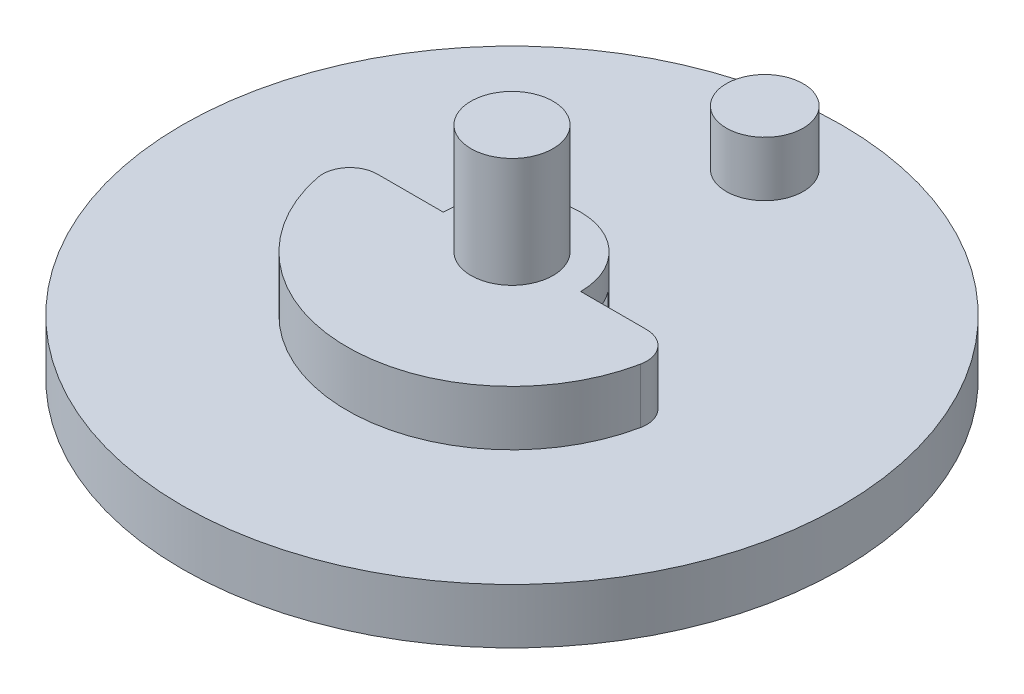
from build123d import *

# Parameters (mm, degrees)
SKETCH1_R                = 12
BOSS_EXTRUDE1_DEPTH      = 2
SKETCH2_R                = 1.5
BOSS_EXTRUDE2_DEPTH      = 2
SKETCH3_R                = 1.5
CUT_EXTRUDE1_DEPTH       = 5
SKETCH4_R                = 4
CUT_EXTRUDE2_DEPTH       = 2
SKETCH5_R                = 1.5
CUT_EXTRUDE3_DEPTH       = 2
SKETCH6_R                = 1.4
BOSS_EXTRUDE3_DEPTH      = 2
SKETCH7_R                = 1.6
CUT_EXTRUDE4_DEPTH       = 2
FILLET1_R                = 1
SKETCH8_R                = 4
BOSS_EXTRUDE7_DEPTH      = 5
SKETCH9_R                = 1.6
BOSS_EXTRUDE8_DEPTH      = 6
BOSS_EXTRUDE8_DEPTH_BACK = 2
SKETCH10_R               = 1.6
SKETCH10_R_2             = 1.495
CUT_EXTRUDE5_DEPTH       = 6
SKETCH11_R               = 4
BOSS_EXTRUDE9_DEPTH      = 2
CUT_EXTRUDE6_DEPTH       = 8
SKETCH13_R               = 6.833450219
CUT_EXTRUDE7_DEPTH       = 1
SKETCH14_R               = 7.033053892
CUT_EXTRUDE8_DEPTH       = 1
SKETCH15_R               = 8.776668046
CUT_EXTRUDE9_DEPTH       = 0.5
CUT_EXTRUDE10_DEPTH      = 2
CUT_EXTRUDE11_DEPTH      = 2


with BuildPart() as part:
    # Sketch1 → Boss-Extrude1 (new body)
    with BuildSketch(Plane(origin=(0, 0, 0), x_dir=(1, 0, 0), z_dir=(0, 1, 0))):
        Circle(SKETCH1_R)
    extrude(amount=BOSS_EXTRUDE1_DEPTH)

    # Sketch2 → Boss-Extrude2 (add)
    with BuildSketch(Plane(origin=(0, 2, 0), x_dir=(1, 0, 0), z_dir=(0, 1, 0))):
        with Locations((0, 9.5)):
            Circle(SKETCH2_R)
        with BuildLine():
            Line((-6, 0), (6, 0))
            ThreePointArc((6, 0), (0, -6), (-6, 0))
        make_face()
    extrude(amount=BOSS_EXTRUDE2_DEPTH)

    # Sketch3 → Cut-Extrude1 (cut)
    with BuildSketch(Plane.XZ):
        Circle(SKETCH3_R)
    extrude(amount=-CUT_EXTRUDE1_DEPTH, mode=Mode.SUBTRACT)

    # Sketch4 → Cut-Extrude2 (cut)
    with BuildSketch(Plane(origin=(0, 2, 0), x_dir=(1, 0, 0), z_dir=(0, 1, 0))):
        Circle(SKETCH4_R)
    extrude(amount=CUT_EXTRUDE2_DEPTH, mode=Mode.SUBTRACT)

    # Sketch5 → Cut-Extrude3 (cut)
    with BuildSketch(Plane(origin=(0, 2, 0), x_dir=(1, 0, 0), z_dir=(0, 1, 0))):
        with Locations((0, 9.5)):
            Circle(SKETCH5_R)
    extrude(amount=CUT_EXTRUDE3_DEPTH, mode=Mode.SUBTRACT)

    # Sketch6 → Boss-Extrude3 (add)
    with BuildSketch(Plane(origin=(0, 2, 0), x_dir=(1, 0, 0), z_dir=(0, 1, 0))):
        with Locations((0, 9.2)):
            Circle(SKETCH6_R)
    extrude(amount=BOSS_EXTRUDE3_DEPTH)

    # Sketch7 → Cut-Extrude4 (cut)
    with BuildSketch(Plane(origin=(0, 2, 0), x_dir=(1, 0, 0), z_dir=(0, 1, 0))):
        Circle(SKETCH7_R)
    extrude(amount=-CUT_EXTRUDE4_DEPTH, mode=Mode.SUBTRACT)

    # Fillet1
    fillet1_edges = [part.edges().sort_by_distance(p)[0] for p in [
        (-6, 3, 0),
        (6, 3, 0),
    ]]
    fillet(fillet1_edges, radius=FILLET1_R)

    # Sketch8 → Boss-Extrude7 (add)
    with BuildSketch(Plane(origin=(0, 0, 0), x_dir=(-1, 0, 0), z_dir=(0, -1, 0))):
        Circle(SKETCH8_R)
        with BuildLine():
            ThreePointArc((0.556776436, -1.5), (0, -1.6), (-0.556776436, -1.5))
            Line((-0.556776436, -1.5), (-2, -1.5))
            ThreePointArc((-2, -1.5), (-2.5, 0), (-2, 1.5))
            Line((-2, 1.5), (-0.556776436, 1.5))
            ThreePointArc((-0.556776436, 1.5), (0, 1.6), (0.556776436, 1.5))
            Line((0.556776436, 1.5), (2, 1.5))
            ThreePointArc((2, 1.5), (2.5, 0), (2, -1.5))
            Line((2, -1.5), (0.556776436, -1.5))
        make_face(mode=Mode.SUBTRACT)
    extrude(amount=BOSS_EXTRUDE7_DEPTH)

    # Sketch9 → Boss-Extrude8 (add, two sides)
    with BuildSketch(Plane(origin=(0, 2, 0), x_dir=(1, 0, 0), z_dir=(0, 1, 0))) as boss_extrude8_sk:
        Circle(SKETCH9_R)
    extrude(amount=BOSS_EXTRUDE8_DEPTH)
    extrude(boss_extrude8_sk.sketch, amount=-BOSS_EXTRUDE8_DEPTH_BACK)

    # Sketch10 → Cut-Extrude5 (cut)
    with BuildSketch(Plane(origin=(0, 8, 0), x_dir=(1, 0, 0), z_dir=(0, 1, 0))):
        Circle(SKETCH10_R)
        Circle(SKETCH10_R_2, mode=Mode.SUBTRACT)
    extrude(amount=-CUT_EXTRUDE5_DEPTH, mode=Mode.SUBTRACT)

    # Sketch11 → Boss-Extrude9 (add)
    with BuildSketch(Plane(origin=(0, 2, 0), x_dir=(1, 0, 0), z_dir=(0, 1, 0))):
        Circle(SKETCH11_R)
    extrude(amount=BOSS_EXTRUDE9_DEPTH)

    # Sketch12 → Cut-Extrude6 (cut)
    with BuildSketch(Plane(origin=(0, -5, 0), x_dir=(-1, 0, 0), z_dir=(0, -1, 0))):
        with BuildLine():
            Line((2, -1.5), (0.556776436, -1.5))
            ThreePointArc((0.556776436, -1.5), (0, -1.6), (-0.556776436, -1.5))
            Line((-0.556776436, -1.5), (-2, -1.5))
            ThreePointArc((-2, -1.5), (-2.5, 0), (-2, 1.5))
            Line((-2, 1.5), (-0.556776436, 1.5))
            ThreePointArc((-0.556776436, 1.5), (0, 1.6), (0.556776436, 1.5))
            Line((0.556776436, 1.5), (2, 1.5))
            ThreePointArc((2, 1.5), (2.5, 0), (2, -1.5))
        make_face()
    extrude(amount=-CUT_EXTRUDE6_DEPTH, mode=Mode.SUBTRACT)

    # Sketch13 → Cut-Extrude7 (cut)
    with BuildSketch(Plane(origin=(0, -5, 0), x_dir=(-1, 0, 0), z_dir=(0, -1, 0))):
        Circle(SKETCH13_R)
    extrude(amount=-CUT_EXTRUDE7_DEPTH, mode=Mode.SUBTRACT)

    # Sketch14 → Cut-Extrude8 (cut)
    with BuildSketch(Plane(origin=(0, -4, 0), x_dir=(-1, 0, 0), z_dir=(0, -1, 0))):
        Circle(SKETCH14_R)
    extrude(amount=-CUT_EXTRUDE8_DEPTH, mode=Mode.SUBTRACT)

    # Sketch15 → Cut-Extrude9 (cut)
    with BuildSketch(Plane(origin=(0, -3, 0), x_dir=(-1, 0, 0), z_dir=(0, -1, 0))):
        Circle(SKETCH15_R)
    extrude(amount=-CUT_EXTRUDE9_DEPTH, mode=Mode.SUBTRACT)

    # Sketch16 → Cut-Extrude10 (cut)
    with BuildSketch(Plane(origin=(0, 4, 0), x_dir=(1, 0, 0), z_dir=(0, 1, 0))):
        with BuildLine():
            Line((-4, 0), (-3, 0))
            ThreePointArc((-3, 0), (0, 3), (3, 0))
            Line((3, 0), (4, 0))
            Line((4, 0), (6.488398176, 5.447999119))
            Line((6.488398176, 5.447999119), (-6.411842689, 6.016687232))
            Line((-6.411842689, 6.016687232), (-4, 0))
        make_face()
    extrude(amount=-CUT_EXTRUDE10_DEPTH, mode=Mode.SUBTRACT)

    # Sketch17 → Cut-Extrude11 (cut)
    with BuildSketch(Plane(origin=(0, 4, 0), x_dir=(1, 0, 0), z_dir=(0, 1, 0))):
        with BuildLine():
            Line((-3, 0), (-2.5, 0))
            ThreePointArc((-2.5, 0), (0, 2.5), (2.5, 0))
            Line((2.5, 0), (3, 0))
            Line((3, 0), (3.695122569, 4.261417823))
            Line((3.695122569, 4.261417823), (-7.0808681, 5.499359859))
            Line((-7.0808681, 5.499359859), (-3, 0))
        make_face()
    extrude(amount=-CUT_EXTRUDE11_DEPTH, mode=Mode.SUBTRACT)


solid = part.part
